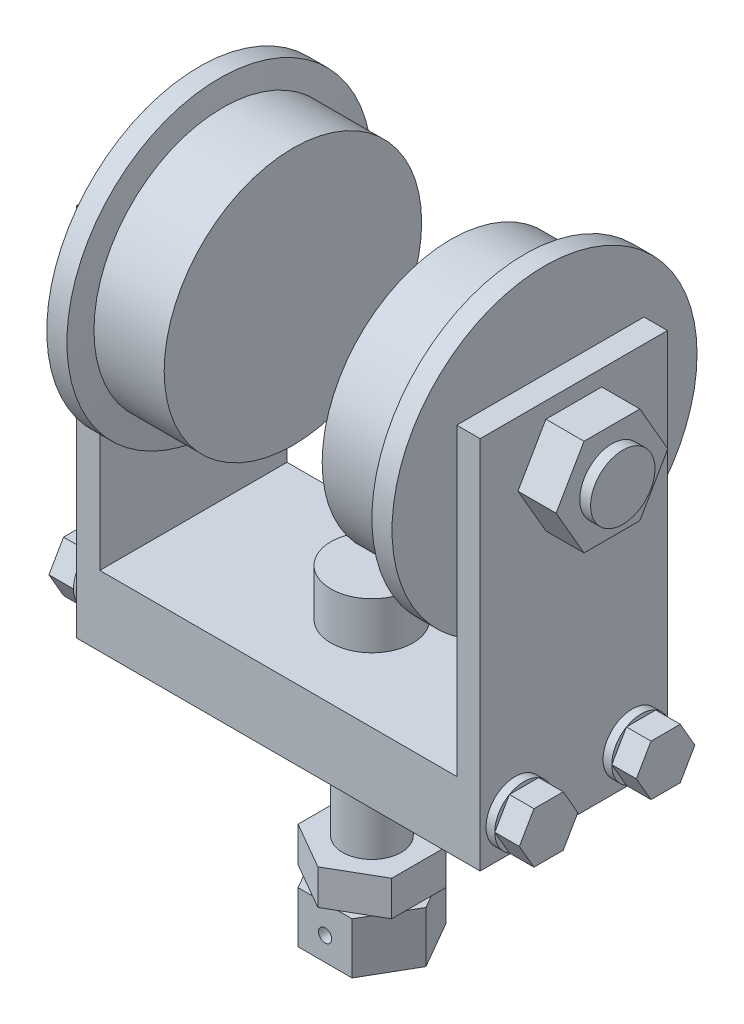
from build123d import *

# Parameters (mm, degrees)
YOKE_CROSS_SECTION_W           = 101.6
YOKE_CROSS_SECTION_H           = 38.1
YOKE_DEPTH                     = 96.8375
SIDEPLATE_PROFILE_W            = 101.6
SIDEPLATE_PROFILE_H            = 203.2
SIDEPLATE_DEPTH                = 12.7
WHEEL_PIN_NUT_DEPTH            = 20.70608
WHEEL_PIN_PROJECTION_PROFILE_R = 17.4625
WHEEL_PIN_PROJECTION_DEPTH     = 5.88264
LOCKNUTS_PROFILE_R             = 15.875
LOCKNUTS_DEPTH                 = 4.7625
SCREWS_DEPTH                   = 13.3223
PROFILE_R                      = 22.225
KING_BOLT_HEAD_DEPTH           = 25.4
DIA_R                          = 15.875
KING_BOLT_DEPTH                = 63.5
KING_BOLT_JAM_NUT_DEPTH        = 19.0754
KING_BOLT_NUT_DEPTH            = 27.8003
SKETCH5_R                      = 15.875
EXTENDED_KING_BOLT_DEPTH       = 6.35
CHAMFER1_SIZE                  = 2.38125
COTTER_PIN_HOLE_REACH          = 110.149
SKETCH7_R                      = 3.571875


with BuildPart() as part:
    # YOKE CROSS SECTION → YOKE (new body)
    with BuildSketch(Plane(origin=(0, 0, 0), x_dir=(0, 0, -1), z_dir=(1, 0, 0))):
        with Locations((0, 19.05)):
            Rectangle(YOKE_CROSS_SECTION_W, YOKE_CROSS_SECTION_H)
    extrude(amount=YOKE_DEPTH)

    # SIDEPLATE PROFILE → SIDEPLATE (add)
    with BuildSketch(Plane(origin=(96.8375, 0, 0), x_dir=(0, 0, -1), z_dir=(1, 0, 0))):
        with Locations((0, 101.6)):
            Rectangle(SIDEPLATE_PROFILE_W, SIDEPLATE_PROFILE_H)
    extrude(amount=SIDEPLATE_DEPTH)

    # WHEEL PIN NUT PROFILE → WHEEL PIN NUT (add)
    with BuildSketch(Plane(origin=(109.5375, 0, 0), x_dir=(0, 0, -1), z_dir=(1, 0, 0))):
        Polygon((30.301663075, 168.275), (15.150831538, 194.51701), (-15.150831538, 194.51701), (-30.301663075, 168.275), (-15.150831538, 142.03299), (15.150831538, 142.03299), align=None)
    extrude(amount=WHEEL_PIN_NUT_DEPTH)

    # WHEEL PIN PROJECTION PROFILE → WHEEL PIN PROJECTION (add)
    with BuildSketch(Plane(origin=(130.24358, 0, 0), x_dir=(0, 0, -1), z_dir=(1, 0, 0))):
        with Locations((0, 168.275)):
            Circle(WHEEL_PIN_PROJECTION_PROFILE_R)
    extrude(amount=WHEEL_PIN_PROJECTION_DEPTH)

    # LOCKNUTS PROFILE → LOCKNUTS (add)
    with BuildSketch(Plane(origin=(109.5375, 0, 0), x_dir=(0, 0, -1), z_dir=(1, 0, 0))):
        with Locations((-31.75, 19.05)):
            Circle(LOCKNUTS_PROFILE_R)
    locknuts = extrude(amount=LOCKNUTS_DEPTH)

    # SCREWS PROFILE → SCREWS (add)
    with BuildSketch(Plane(origin=(114.3, 0, 0), x_dir=(0, 0, -1), z_dir=(1, 0, 0))):
        Polygon((-15.875465673, 19.05), (-23.812732837, 32.79775), (-39.687267163, 32.79775), (-47.624534327, 19.05), (-39.687267163, 5.30225), (-23.812732837, 5.30225), align=None)
    screws = extrude(amount=SCREWS_DEPTH)

    # PROFILE → KING BOLT HEAD (add)
    with BuildSketch(Plane(origin=(0, 38.1, 0), x_dir=(-1, 0, 0), z_dir=(0, 1, 0))):
        with Locations(Location((0, 0, 0), (0, 0, 90))):  # turned: the seam where the file's is
            Circle(PROFILE_R)
    extrude(amount=KING_BOLT_HEAD_DEPTH)

    # Mirror1: LOCKNUTS, SCREWS across plane
    add(locknuts.mirror(Plane.XY))
    add(screws.mirror(Plane.XY))

    # Mirror5: part across plane


with BuildPart() as part_1:
    add(part.part)
    add(part.part.mirror(Plane(origin=(0, 0, 0), x_dir=(0, 0, 1), z_dir=(1, 0, 0))))

    # DIA. → KING BOLT (add)
    with BuildSketch(Plane.XZ):
        with Locations(Location((0, 0, 0), (0, 0, 90))):  # turned: the seam where the file's is
            Circle(DIA_R)
    extrude(amount=KING_BOLT_DEPTH)

    # KING BOLT JAN NUT PROFILE → KING BOLT JAM NUT (add)
    with BuildSketch(Plane.XZ.offset(63.5)):
        Polygon((0, -29.329393675), (25.4, -14.664696837), (25.4, 14.664696837), (0, 29.329393675), (-25.4, 14.664696837), (-25.4, -14.664696837), align=None)
    extrude(amount=KING_BOLT_JAM_NUT_DEPTH)

    # KING BOLT NUT PROFILE → KING BOLT NUT (add)
    with BuildSketch(Plane.XZ.offset(82.5754)):
        Polygon((29.329393675, 0), (14.664696837, 25.4), (-14.664696837, 25.4), (-29.329393675, 0), (-14.664696837, -25.4), (14.664696837, -25.4), align=None)
    extrude(amount=KING_BOLT_NUT_DEPTH)

    # Sketch5 → EXTENDED KING BOLT (add)
    with BuildSketch(Plane.XZ.offset(110.3757)):
        with Locations(Location((0, 0, 0), (0, 0, 90))):  # turned: the seam where the file's is
            Circle(SKETCH5_R)
    extrude(amount=EXTENDED_KING_BOLT_DEPTH)

    # Chamfer1
    chamfer1_edges = [part_1.edges().sort_by_distance(p)[0] for p in [
        (0, -116.7257, -15.875),
    ]]
    chamfer(chamfer1_edges, length=CHAMFER1_SIZE)

    # Sketch6 → WHEEL (revolve)
    with BuildSketch(Plane.XY, mode=Mode.PRIVATE) as wheel_sk:
        Polygon((96.8375, 168.275), (42.8625, 168.275), (42.8625, 238.125), (80.9625, 238.125), (82.747368601, 251.024359069), (93.6625, 251.024359069), (93.6625, 193.675), (96.8375, 193.675), align=None)
    wheel = revolve(wheel_sk.sketch.rotate(Axis((96.8375, 168.275, 0), (-1, 0, 0)), 90), axis=Axis((96.8375, 168.275, 0), (-1, 0, 0)))  # turned: the seam where the file's is

    # Mirror6: WHEEL across plane
    add(wheel.mirror(Plane(origin=(0, 0, 0), x_dir=(0, 0, 1), z_dir=(1, 0, 0))))

    # Sketch7 → COTTER PIN HOLE (cut, up to next)
    with BuildSketch(Plane.XY.offset(25.4), mode=Mode.PRIVATE) as cotter_pin_hole_sk1:
        with Locations((0, -97.6757)):
            Circle(SKETCH7_R)
    cotter_pin_hole_tool1 = extrude(cotter_pin_hole_sk1.sketch, amount=-COTTER_PIN_HOLE_REACH, mode=Mode.PRIVATE) & part_1.part
    add(cotter_pin_hole_tool1.solids().sort_by_distance((0, -97.6757, 25.4))[0], mode=Mode.SUBTRACT)


solid = part_1.part
